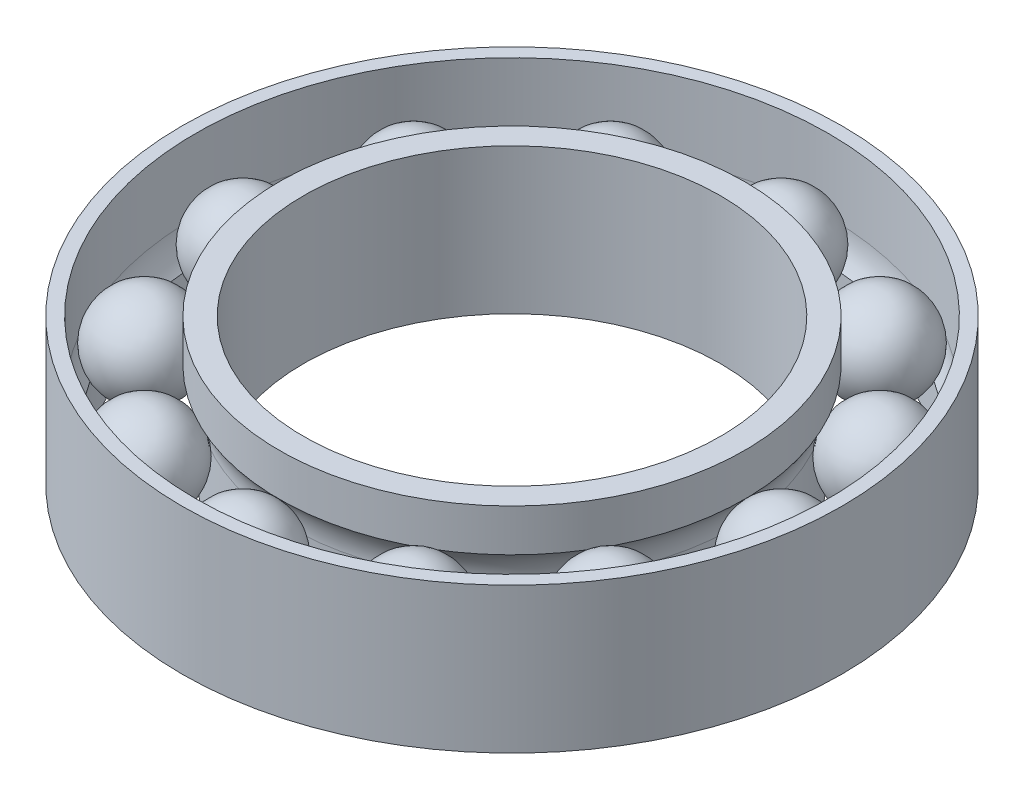
from build123d import *

# Parameters (mm, degrees)
CIRPATTERN1_COUNT = 12


with BuildPart() as part:
    # Sketch1 → Revolve1 (revolve)
    with BuildSketch(Plane.XY):
        with BuildLine():
            Line((4.3, 0), (4.575, 0))
            Line((4.575, 0), (4.575, 1.504924226))
            ThreePointArc((4.575, 1.504924226), (4.632973555, 1.836115259), (4.8, 2.127921016))
            Line((4.8, 2.127921016), (4.8, 3))
            Line((4.8, 3), (4.3, 3))
            Line((4.3, 3), (4.3, 0))
        make_face()
        with BuildLine():
            Line((6.8, 0), (6.8, 3))
            Line((6.8, 3), (6.525, 3))
            Line((6.525, 3), (6.525, 1.504924226))
            ThreePointArc((6.525, 1.504924226), (6.467026445, 1.173733194), (6.3, 0.881927437))
            Line((6.3, 0.881927437), (6.3, 0))
            Line((6.3, 0), (6.8, 0))
        make_face()
    revolve(axis=Axis((0, 3, 0), (0, 1, 0)))


with BuildPart() as body_2:
    # Sketch2 → Revolve2 (revolve)
    with BuildSketch(Plane.XY):
        with BuildLine():
            Line((5.55, 2.475), (5.55, 0.525))
            ThreePointArc((5.55, 0.525), (6.525, 1.5), (5.55, 2.475))
        make_face()
    revolve(axis=Axis((5.55, 0.243856037, 0), (0, 1, 0)))


with BuildPart() as cirpattern1_1:
    # CirPattern1: pattern copy
    add(body_2.part.rotate(Axis((0, 0, 0), (0, 1, 0)), 1 * 360 / CIRPATTERN1_COUNT))


with BuildPart() as cirpattern1_2:
    # CirPattern1: pattern copy
    add(body_2.part.rotate(Axis((0, 0, 0), (0, 1, 0)), 2 * 360 / CIRPATTERN1_COUNT))


with BuildPart() as cirpattern1_3:
    # CirPattern1: pattern copy
    add(body_2.part.rotate(Axis((0, 0, 0), (0, 1, 0)), 3 * 360 / CIRPATTERN1_COUNT))


with BuildPart() as cirpattern1_4:
    # CirPattern1: pattern copy
    add(body_2.part.rotate(Axis((0, 0, 0), (0, 1, 0)), 4 * 360 / CIRPATTERN1_COUNT))


with BuildPart() as cirpattern1_5:
    # CirPattern1: pattern copy
    add(body_2.part.rotate(Axis((0, 0, 0), (0, 1, 0)), 5 * 360 / CIRPATTERN1_COUNT))


with BuildPart() as cirpattern1_6:
    # CirPattern1: pattern copy
    add(body_2.part.rotate(Axis((0, 0, 0), (0, 1, 0)), 6 * 360 / CIRPATTERN1_COUNT))


with BuildPart() as cirpattern1_7:
    # CirPattern1: pattern copy
    add(body_2.part.rotate(Axis((0, 0, 0), (0, 1, 0)), 7 * 360 / CIRPATTERN1_COUNT))


with BuildPart() as cirpattern1_8:
    # CirPattern1: pattern copy
    add(body_2.part.rotate(Axis((0, 0, 0), (0, 1, 0)), 8 * 360 / CIRPATTERN1_COUNT))


with BuildPart() as cirpattern1_9:
    # CirPattern1: pattern copy
    add(body_2.part.rotate(Axis((0, 0, 0), (0, 1, 0)), 9 * 360 / CIRPATTERN1_COUNT))


with BuildPart() as cirpattern1_10:
    # CirPattern1: pattern copy
    add(body_2.part.rotate(Axis((0, 0, 0), (0, 1, 0)), 10 * 360 / CIRPATTERN1_COUNT))


with BuildPart() as cirpattern1_11:
    # CirPattern1: pattern copy
    add(body_2.part.rotate(Axis((0, 0, 0), (0, 1, 0)), 11 * 360 / CIRPATTERN1_COUNT))


solid = Compound([part.part, body_2.part, cirpattern1_1.part, cirpattern1_2.part, cirpattern1_3.part, cirpattern1_4.part, cirpattern1_5.part, cirpattern1_6.part, cirpattern1_7.part, cirpattern1_8.part, cirpattern1_9.part, cirpattern1_10.part, cirpattern1_11.part])
